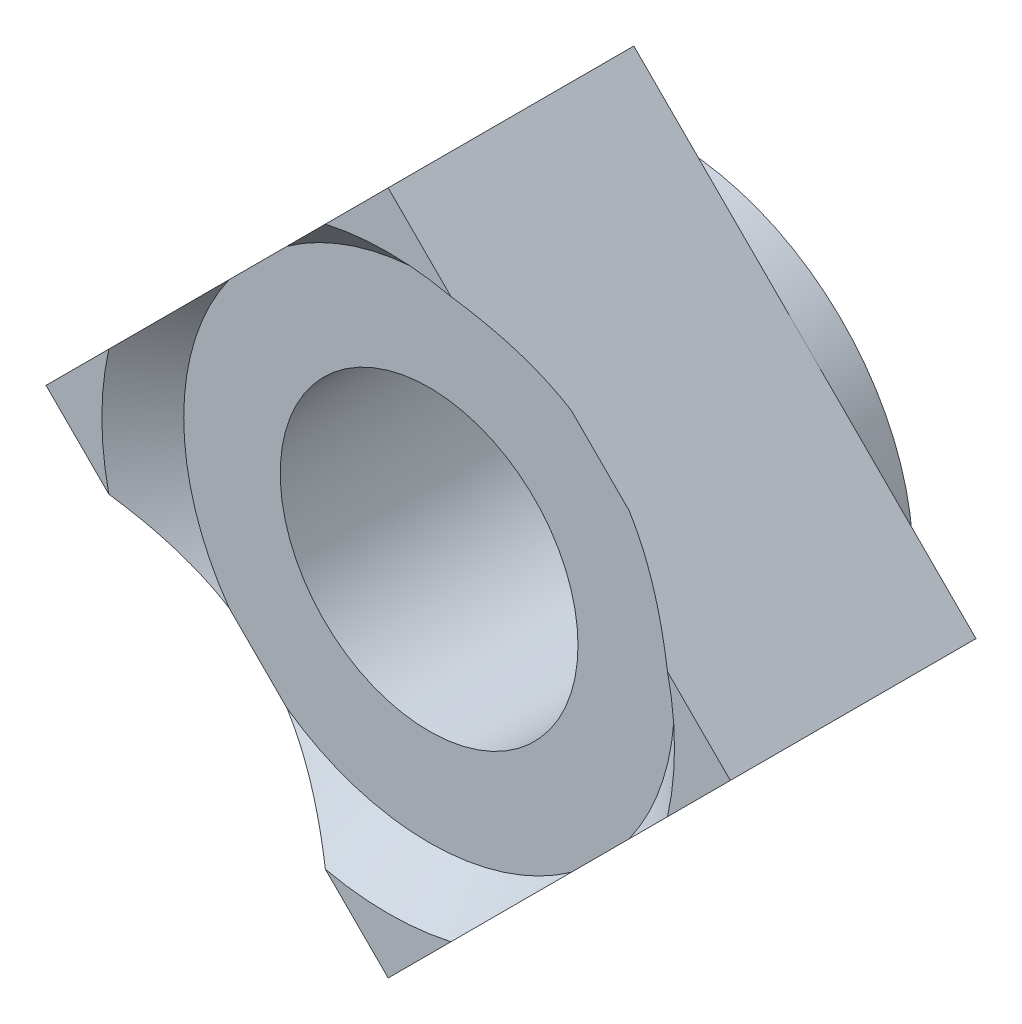
from build123d import *

# Parameters (mm, degrees)
SKETCH_1_R          = 6.5
EXTRUDE_1_DEPTH     = 1
EXTRUDE_2_DEPTH     = 5.5
EXTRUDE_3_DEPTH     = 1.1
SKETCH_5_R          = 4
CUT_EXTRUDE_1_DEPTH = 7.5
SKETCH_6_R          = 5.11
CUT_EXTRUDE_2_DEPTH = 0.2


with BuildPart() as part:
    # 草图1 → 拉伸1 (new body)
    with BuildSketch(Plane.XY):
        Circle(SKETCH_1_R)
    extrude(amount=EXTRUDE_1_DEPTH)

    # 草图2 → 拉伸2 (add)
    with BuildSketch(Plane.XY.offset(1)):
        Polygon((0, 9.192388155), (-9.192388155, 0), (0, -9.192388155), (9.192388155, 0), align=None)
    extrude(amount=EXTRUDE_2_DEPTH)

    # 草图3 → 拉伸3 (add)
    with BuildSketch(Plane.XY.offset(6.5)):
        Polygon((9.192388155, 0), (0, 9.192388155), (-9.192388155, 0), (0, -9.192388155), align=None)
    extrude(amount=EXTRUDE_3_DEPTH)

    # 草图4 → 切除-旋转1 (revolve, cut)
    with BuildSketch(Plane(origin=(0, 0, 0), x_dir=(0, 0, -1), z_dir=(1, 0, 0))):
        Polygon((-6.5, 6.592388155), (-6.5, 0), (-7.6, 0), (-7.6, 7.692388155), align=None)
    revolve(axis=Axis((0, 0, 0), (0, 0, 1)), mode=Mode.SUBTRACT)

    # 草图5 → 切除-拉伸1 (cut, through all)
    with BuildSketch(Plane.XY.offset(6.5)):
        Circle(SKETCH_5_R)
    extrude(amount=-CUT_EXTRUDE_1_DEPTH, mode=Mode.SUBTRACT)

    # 草图6 → 切除-拉伸2 (cut)
    with BuildSketch(Plane(origin=(0, 0, 0), x_dir=(-1, 0, 0), z_dir=(0, 0, -1))):
        Circle(SKETCH_6_R)
    extrude(amount=-CUT_EXTRUDE_2_DEPTH, mode=Mode.SUBTRACT)


solid = part.part
